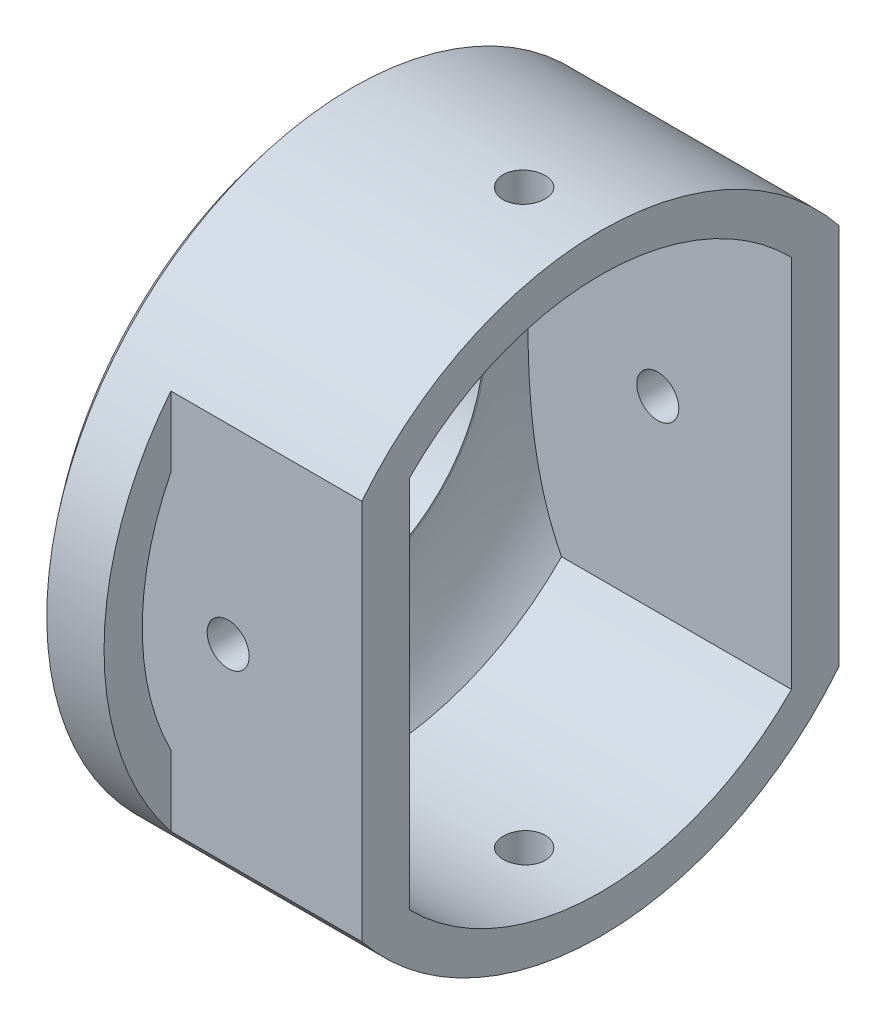
from build123d import *

# Parameters (mm, degrees)
SHELL1_T                        = -2
CUT_EXTRUDE1_REACH              = 4
SKETCH2_R                       = 7.9
SKETCH3_W                       = 2.5
SKETCH3_H                       = 19.974984356
BOSS_EXTRUDE1_DEPTH             = 10
BOSS_EXTRUDE1_DIRECTION_2_REACH = 8
SKETCH4_R                       = 1.1
CUT_EXTRUDE2_DEPTH              = 29.5000001
BOSS_EXTRUDE3_DEPTH             = 10
SKETCH6_R                       = 1.1
CUT_EXTRUDE3_DEPTH              = 22.5


with BuildPart() as part:
    # Sketch1 → Revolve1 (revolve)
    with BuildSketch(Plane.XY):
        with BuildLine():
            Line((0, 0), (0, 16))
            Line((0, 16), (-3, 16))
            ThreePointArc((-3, 16), (-5.225338327, 12.272001873), (-6, 8))
            Line((-6, 8), (-6, 0))
            Line((-6, 0), (0, 0))
        make_face()
    revolve(axis=Axis((0, 0, 0), (-1, 0, 0)))

    # Shell1
    shell1_openings = [part.faces().sort_by_distance(p)[0] for p in [
        (0, 16, 0),
    ]]
    offset(amount=SHELL1_T, openings=shell1_openings, kind=Kind.INTERSECTION)

    # Sketch2 → Cut-Extrude1 (cut, up to next)
    with BuildSketch(Plane(origin=(-4, 0, 0), x_dir=(0, 0, -1), z_dir=(1, 0, 0)), mode=Mode.PRIVATE) as cut_extrude1_sk1:
        Circle(SKETCH2_R)
    cut_extrude1_tool1 = extrude(cut_extrude1_sk1.sketch, amount=-CUT_EXTRUDE1_REACH, mode=Mode.PRIVATE) & part.part
    add(cut_extrude1_tool1.solids().sort_by_distance((-4, 0, 0))[0], mode=Mode.SUBTRACT)

    # Sketch3 → Boss-Extrude1 (add)
    with BuildSketch(Plane(origin=(0, 0, 0), x_dir=(0, 0, -1), z_dir=(1, 0, 0))):
        with Locations((-11.25, 0)):
            Rectangle(SKETCH3_W, SKETCH3_H)
        with Locations((11.25, 0)):
            Rectangle(SKETCH3_W, SKETCH3_H)
    extrude(amount=BOSS_EXTRUDE1_DEPTH)

    # Sketch3 → Boss-Extrude1 direction 2 (add, up to next)
    with BuildSketch(Plane(origin=(0, 0, 0), x_dir=(0, 0, -1), z_dir=(1, 0, 0)), mode=Mode.PRIVATE) as boss_extrude1_direction_2_sk1:
        with Locations((-11.25, 0)):
            Rectangle(SKETCH3_W, SKETCH3_H)
    boss_extrude1_direction_2_tool1 = extrude(boss_extrude1_direction_2_sk1.sketch, amount=-BOSS_EXTRUDE1_DIRECTION_2_REACH, mode=Mode.PRIVATE) - part.part
    add(boss_extrude1_direction_2_tool1.solids().sort_by_distance((0, 0, 11.25))[0])
    # Sketch3 → Boss-Extrude1 direction 2 (add, up to next)
    with BuildSketch(Plane(origin=(0, 0, 0), x_dir=(0, 0, -1), z_dir=(1, 0, 0)), mode=Mode.PRIVATE) as boss_extrude1_direction_2_sk2:
        with Locations((11.25, 0)):
            Rectangle(SKETCH3_W, SKETCH3_H)
    boss_extrude1_direction_2_tool2 = extrude(boss_extrude1_direction_2_sk2.sketch, amount=-BOSS_EXTRUDE1_DIRECTION_2_REACH, mode=Mode.PRIVATE) - part.part
    add(boss_extrude1_direction_2_tool2.solids().sort_by_distance((0, 0, -11.25))[0])

    # Sketch4 → Cut-Extrude2 (cut, through all)
    with BuildSketch(Plane.XY.offset(12.5)):
        with Locations((3, 0)):
            Circle(SKETCH4_R)
    extrude(amount=-CUT_EXTRUDE2_DEPTH, mode=Mode.SUBTRACT)

    # Sketch5 → Boss-Extrude3 (add)
    with BuildSketch(Plane(origin=(0, 0, 0), x_dir=(0, 0, -1), z_dir=(1, 0, 0))):
        with BuildLine():
            Line((10, 9.797958971), (10, 9.987492178))
            Line((10, 9.987492178), (12.5, 9.987492178))
            ThreePointArc((12.5, 9.987492178), (0, 16), (-12.5, 9.987492178))
            Line((-12.5, 9.987492178), (-10, 9.987492178))
            Line((-10, 9.987492178), (-10, 9.797958971))
            ThreePointArc((-10, 9.797958971), (0, 14), (10, 9.797958971))
        make_face()
        with BuildLine():
            Line((12.5, -9.987492178), (10, -9.987492178))
            Line((10, -9.987492178), (10, -9.797958971))
            ThreePointArc((10, -9.797958971), (0, -14), (-10, -9.797958971))
            Line((-10, -9.797958971), (-10, -9.987492178))
            Line((-10, -9.987492178), (-12.5, -9.987492178))
            ThreePointArc((-12.5, -9.987492178), (0, -16), (12.5, -9.987492178))
        make_face()
    extrude(amount=BOSS_EXTRUDE3_DEPTH)

    # Sketch6 → Cut-Extrude3 (cut, symmetric)
    with BuildSketch(Plane(origin=(0, 0, 0), x_dir=(1, 0, 0), z_dir=(0, 1, 0))):
        with Locations((6, 0)):
            Circle(SKETCH6_R)
    extrude(amount=CUT_EXTRUDE3_DEPTH, both=True, mode=Mode.SUBTRACT)


solid = part.part
